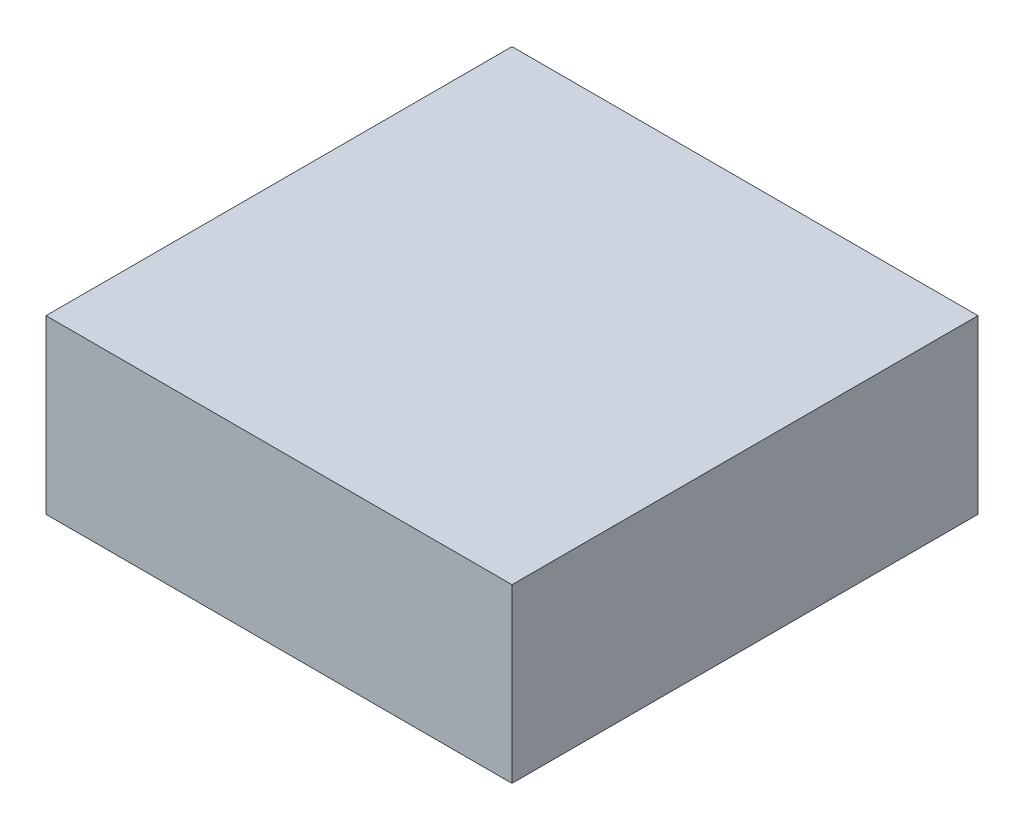
from build123d import *

# Parameters (mm, degrees)
SKETCH1_W           = 1.625
SKETCH1_H           = 1.625
BOSS_EXTRUDE1_DEPTH = 0.6


with BuildPart() as part:
    # Sketch1 → Boss-Extrude1 (new body)
    with BuildSketch(Plane(origin=(0, 0, 0), x_dir=(1, 0, 0), z_dir=(0, 1, 0))):
        Rectangle(SKETCH1_W, SKETCH1_H)
    extrude(amount=BOSS_EXTRUDE1_DEPTH)


solid = part.part
